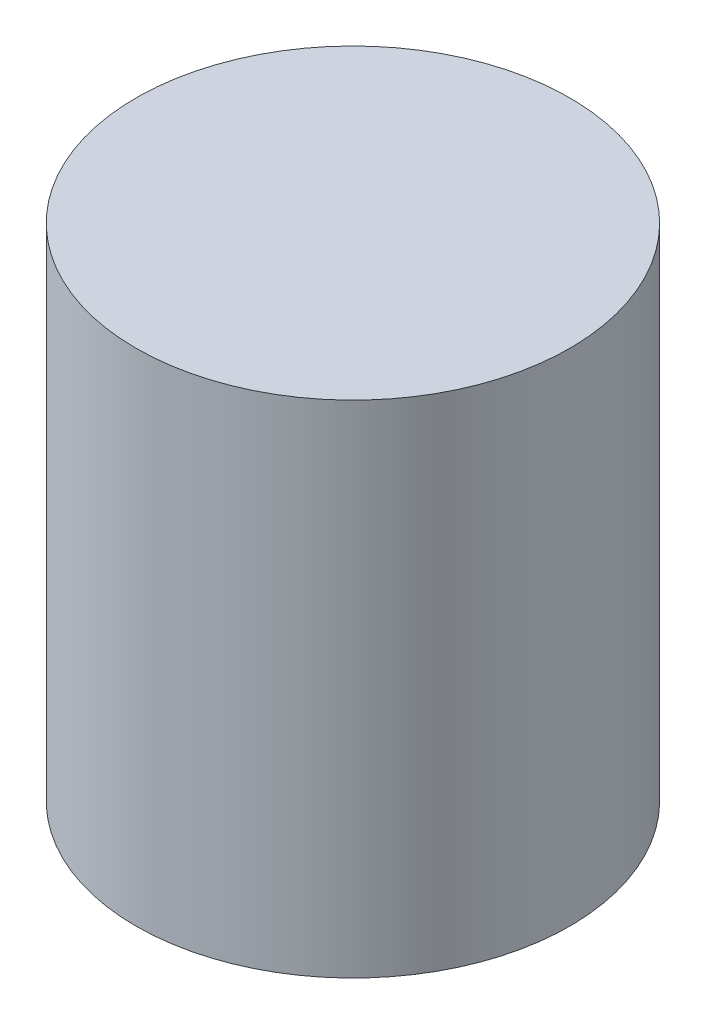
from build123d import *

# Parameters (mm, degrees)
SKETCH1_R           = 6.5
BOSS_EXTRUDE1_DEPTH = 15
SKETCH2_R           = 3
CUT_EXTRUDE1_DEPTH  = 10


with BuildPart() as part:
    # Sketch1 → Boss-Extrude1 (new body)
    with BuildSketch(Plane(origin=(0, 0, 0), x_dir=(1, 0, 0), z_dir=(0, 1, 0))):
        Circle(SKETCH1_R)
    extrude(amount=BOSS_EXTRUDE1_DEPTH)

    # Sketch2 → Cut-Extrude1 (cut)
    with BuildSketch(Plane.XZ):
        Circle(SKETCH2_R)
    extrude(amount=-CUT_EXTRUDE1_DEPTH, mode=Mode.SUBTRACT)


solid = part.part
